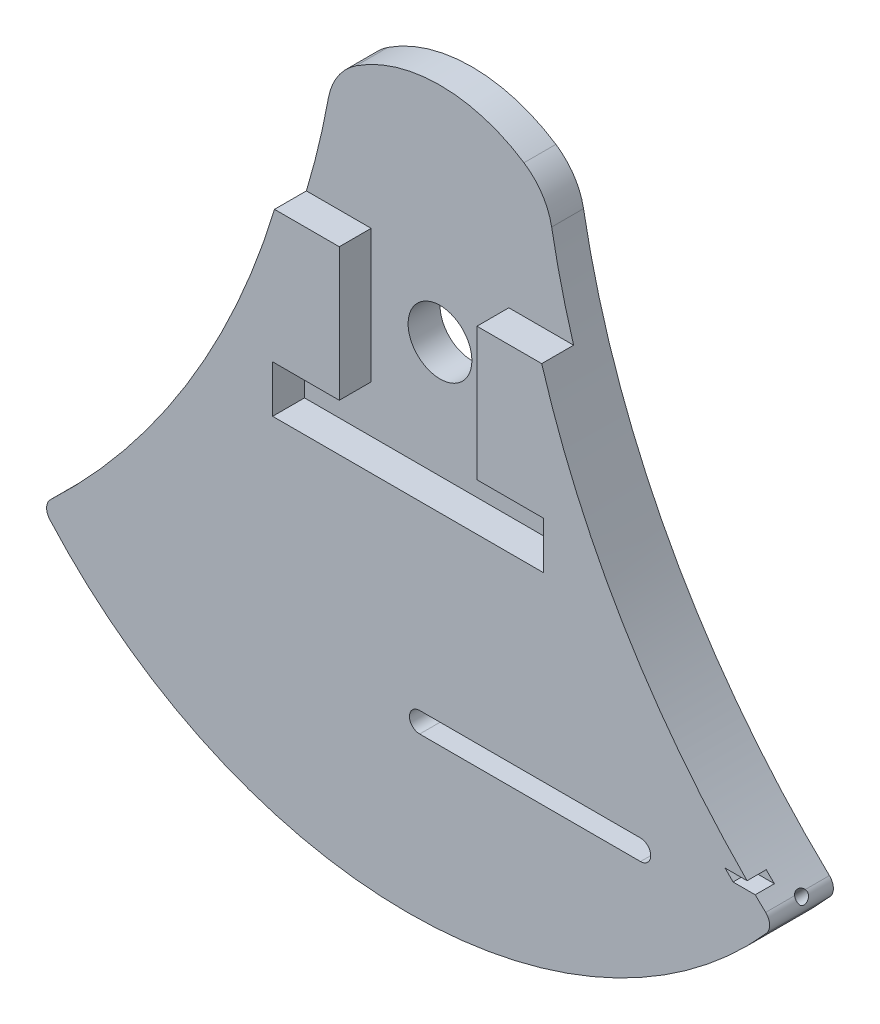
from build123d import *

# Parameters (mm, degrees)
BODY_DEPTH            = 10
SKETCH2_R             = 5
ATTACHMENT_HOLE_DEPTH = 96.00466041
WRAP1_SECTION_W       = 3
WRAP1_SECTION_H       = 6.4106076
WRAP1_ANGLE           = 84.831127775
FILLET3_R             = 2
FILLET4_R             = 2
HORIZ_SLOT_DEPTH      = 95.541676532
CUT_EXTRUDE15_DEPTH   = 3
CUT_EXTRUDE16_DEPTH   = 95.541676532
CUT_EXTRUDE17_DEPTH   = 5
FILLET5_R             = 10
SKETCH31_R            = 0.95
CUT_EXTRUDE24_DEPTH   = 95.541676532
SKETCH21_R            = 0.90381
CUT_EXTRUDE25_DEPTH   = 111.125701877
SKETCH33_R            = 1.625
CUT_EXTRUDE27_DEPTH   = 22.35


with BuildPart() as part:
    # Sketch1 → Body (new body)
    with BuildSketch(Plane.XY):
        with BuildLine():
            ThreePointArc((-57.453333234, -48.209070726), (-24.034507314, 1.033281591), (-16, 60))
            ThreePointArc((-16, 60), (0, 74.927440201), (16, 60))
            ThreePointArc((16, 60), (24.034507314, 1.033281591), (57.453333234, -48.209070726))
            ThreePointArc((57.453333234, -48.209070726), (0, -75), (-57.453333234, -48.209070726))
        make_face()
    extrude(amount=BODY_DEPTH)

    # Sketch2 → Attachment Hole (cut, through all)
    with BuildSketch(Plane.XY.offset(10)):
        Circle(SKETCH2_R)
    extrude(amount=-ATTACHMENT_HOLE_DEPTH, mode=Mode.SUBTRACT)

    # Wrap1 section (on wrap section) → Wrap1 (revolve, cut)
    with BuildSketch(Plane(origin=(0, 0, 0), x_dir=(0.7134885867247005, -0.7006668513734539, 0), z_dir=(0.7006668513734539, 0.7134885867247005, 0))):
        with Locations((73.5, -5.0694594)):
            Rectangle(WRAP1_SECTION_W, WRAP1_SECTION_H)
    revolve(axis=Axis((0, 0, 0), (0, 0, -1)), revolution_arc=WRAP1_ANGLE, mode=Mode.SUBTRACT)

    # Fillet3
    fillet3_edges = [part.edges().sort_by_distance(p)[0] for p in [
        (-57.453333234, -48.209070726, 5),
    ]]
    fillet(fillet3_edges, radius=FILLET3_R)

    # Fillet4
    fillet4_edges = [part.edges().sort_by_distance(p)[0] for p in [
        (57.453333234, -48.209070726, 5),
    ]]
    fillet(fillet4_edges, radius=FILLET4_R)

    # Sketch23 → Horiz Slot (cut, through all)
    with BuildSketch(Plane.XY.offset(10)):
        with BuildLine():
            Line((1.812113949, -46.609070726), (36.441177813, -46.609070726))
            ThreePointArc((36.441177813, -46.609070726), (38.041177813, -48.209070726), (36.441177813, -49.809070726))
            Line((36.441177813, -49.809070726), (1.812113949, -49.809070726))
            ThreePointArc((1.812113949, -49.809070726), (0.212113949, -48.209070726), (1.812113949, -46.609070726))
        make_face()
    extrude(amount=-HORIZ_SLOT_DEPTH, mode=Mode.SUBTRACT)

    # Sketch26 → Cut-Extrude15 (cut)
    with BuildSketch(Plane.XY.offset(10)):
        Polygon((54.427367135, -45.332225497), (50.951636705, -45.332225497), (49.699997105, -44.061296863), (53.150528739, -44.061296863), align=None)
    extrude(amount=-CUT_EXTRUDE15_DEPTH, mode=Mode.SUBTRACT)

    # Sketch27 → Cut-Extrude16 (cut, through all)
    with BuildSketch(Plane.XY.offset(10)):
        with BuildLine():
            ThreePointArc((-16.918727247, 27.887892651), (-15.465829132, 43.915521308), (-16, 60))
            ThreePointArc((-16, 60), (0, 74.927440201), (16, 60))
            ThreePointArc((16, 60), (15.465829132, 43.915521308), (16.918727247, 27.887892651))
            ThreePointArc((16.918727247, 27.887892651), (0, 34.895858935), (-16.918727247, 27.887892651))
        make_face()
    extrude(amount=-CUT_EXTRUDE16_DEPTH, mode=Mode.SUBTRACT)

    # Sketch17 → Cut-Extrude17 (cut)
    with BuildSketch(Plane.XY.offset(10)):
        with BuildLine():
            Line((-21.243201492, 10.060294876), (-10.792899418, 10.060294876))
            Line((-10.792899418, 10.060294876), (-10.792899418, -10.792899418))
            Line((-10.792899418, -10.792899418), (-21.241207195, -10.792899418))
            Line((-21.241207195, -10.792899418), (-21.241207195, -18.192446802))
            Line((-21.241207195, -18.192446802), (21.241207195, -18.192446802))
            Line((21.241207195, -18.192446802), (21.241207195, -10.792899418))
            Line((21.241207195, -10.792899418), (10.792899418, -10.792899418))
            Line((10.792899418, -10.792899418), (10.792899418, 10.060294876))
            Line((10.792899418, 10.060294876), (21.243201492, 10.060294876))
            ThreePointArc((21.243201492, 10.060294876), (18.825884313, 18.91221851), (16.918727247, 27.887892651))
            ThreePointArc((16.918727247, 27.887892651), (0, 34.895858935), (-16.918727247, 27.887892651))
            ThreePointArc((-16.918727247, 27.887892651), (-18.825884313, 18.91221851), (-21.243201492, 10.060294876))
        make_face()
    extrude(amount=-CUT_EXTRUDE17_DEPTH, mode=Mode.SUBTRACT)

    # Fillet5
    fillet5_edges = [part.edges().sort_by_distance(p)[0] for p in [
        (16.918727247, 27.887892651, 2.5),
        (-16.918727247, 27.887892651, 2.5),
    ]]
    fillet(fillet5_edges, radius=FILLET5_R)

    # Sketch31 → Cut-Extrude24 (cut, through all)
    with BuildSketch(Plane(origin=(0, 0, 0), x_dir=(0.7134885867247006, -0.7006668513734536, 0), z_dir=(-0.7006668513734536, -0.7134885867247006, 0))):
        with Locations((73.323950442, 4.61946028)):
            Circle(SKETCH31_R)
    extrude(amount=-CUT_EXTRUDE24_DEPTH, mode=Mode.SUBTRACT)

    # Sketch21 → Cut-Extrude25 (cut, through all)
    with BuildSketch(Plane(origin=(0, -58.989931303, 0), x_dir=(-1, 0, 0), z_dir=(0, -1, 0))):
        with Locations(Location((53.296998856, -5.37681, 0), (0, 0, 180))):
            Circle(SKETCH21_R)
    extrude(amount=-CUT_EXTRUDE25_DEPTH, mode=Mode.SUBTRACT)

    # Sketch33 → Cut-Extrude27 (cut)
    with BuildSketch(Plane(origin=(0, -28.585713625, 0), x_dir=(-1, 0, 0), z_dir=(0, -1, 0))):
        with Locations((53.296998856, -5.376810807)):
            Circle(SKETCH33_R)
    extrude(amount=CUT_EXTRUDE27_DEPTH, mode=Mode.SUBTRACT)


solid = part.part
